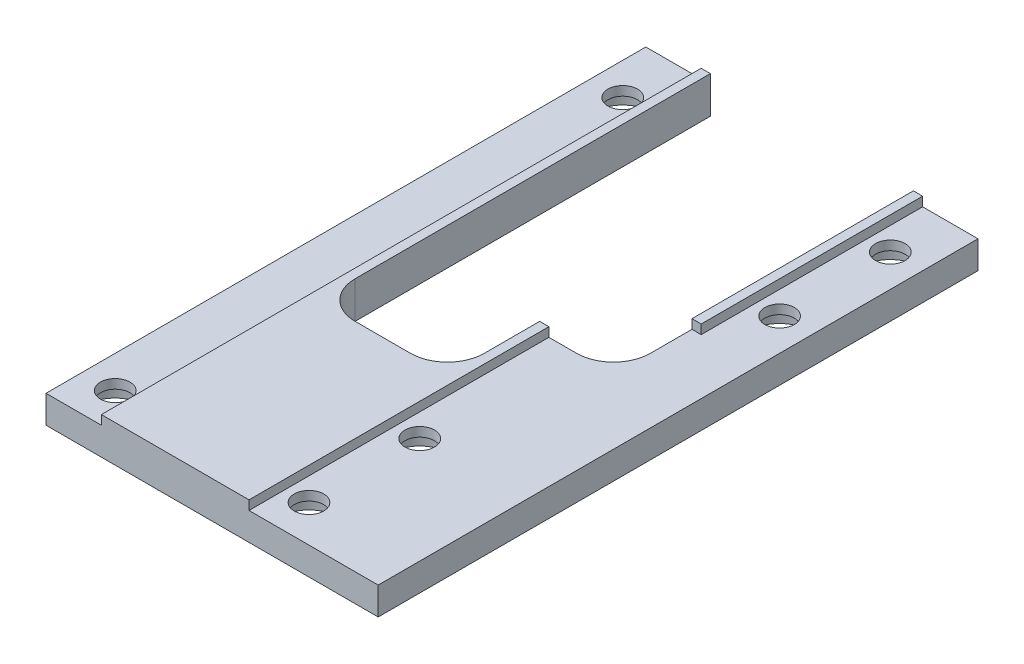
from build123d import *

# Parameters (mm, degrees)
SKIZZE1_W                                            = 36
SKIZZE1_H                                            = 65
AUFSATZ_LINEAR_AUSTRAGEN1_DEPTH                      = 4
SKIZZE2_W                                            = 6
SKIZZE2_H                                            = 65
SCHNITT_LINEAR_AUSTRAGEN1_DEPTH                      = 1
SKIZZE2_3_W                                          = 14
SKIZZE2_3_H                                          = 10
SCHNITT_LINEAR_AUSTRAGEN2_DEPTH                      = 38.366428783
VERRUNDUNG1_R                                        = 4
STIRNSENKUNG_F_R_M3_ZYLINDERSCHRAUBE_MIT_D           = 3.2
STIRNSENKUNG_F_R_M3_ZYLINDERSCHRAUBE_MIT_CBORE_D     = 6.5
STIRNSENKUNG_F_R_M3_ZYLINDERSCHRAUBE_MIT_CBORE_DEPTH = 2


with BuildPart() as part:
    # Skizze1 → Aufsatz-Linear austragen1 (new body)
    with BuildSketch(Plane(origin=(0, 0, 0), x_dir=(1, 0, 0), z_dir=(0, 1, 0))):
        Rectangle(SKIZZE1_W, SKIZZE1_H)
    extrude(amount=AUFSATZ_LINEAR_AUSTRAGEN1_DEPTH)

    # Skizze2 → Schnitt-Linear austragen1 (cut)
    with BuildSketch(Plane(origin=(0, 4, 0), x_dir=(1, 0, 0), z_dir=(0, 1, 0))):
        with Locations((-15, 0)):
            Rectangle(SKIZZE2_W, SKIZZE2_H)
        Polygon((18, 32.5), (12, 32.5), (12, 8.5), (4, 8.5), (4, -32.5), (18, -32.5), align=None)
    extrude(amount=-SCHNITT_LINEAR_AUSTRAGEN1_DEPTH, mode=Mode.SUBTRACT)

    # Skizze2_3 → Schnitt-Linear austragen2 (cut, through all)
    with BuildSketch(Plane(origin=(0, 4, 0), x_dir=(1, 0, 0), z_dir=(0, 1, 0))):
        Polygon((11, 32.5), (-11, 32.5), (-11, 0), (3, 0), (11, 0), align=None)
        with Locations((-4, -5)):
            Rectangle(SKIZZE2_3_W, SKIZZE2_3_H)
    extrude(amount=-SCHNITT_LINEAR_AUSTRAGEN2_DEPTH, mode=Mode.SUBTRACT)

    # Verrundung1
    verrundung1_edges = [part.edges().sort_by_distance(p)[0] for p in [
        (11, 1.5, 0),
        (3, 2, 10),
        (-11, 2, 10),
    ]]
    fillet(verrundung1_edges, radius=VERRUNDUNG1_R)

    # Stirnsenkung für  M3 Zylinderschraube mit Schlitz/Kreuzschlitz1 (through all)
    with Locations(Plane(origin=(0, 0, 0), x_dir=(-1, 0, 0), z_dir=(0, -1, 0))):
        with Locations((14.5, -28.5), (14.5, 26.5), (-14.5, 26.5), (-6.5, -28.5), (-6.5, -16.5), (-14.5, 14.5)):
            CounterBoreHole(STIRNSENKUNG_F_R_M3_ZYLINDERSCHRAUBE_MIT_D / 2, STIRNSENKUNG_F_R_M3_ZYLINDERSCHRAUBE_MIT_CBORE_D / 2, STIRNSENKUNG_F_R_M3_ZYLINDERSCHRAUBE_MIT_CBORE_DEPTH)


solid = part.part
